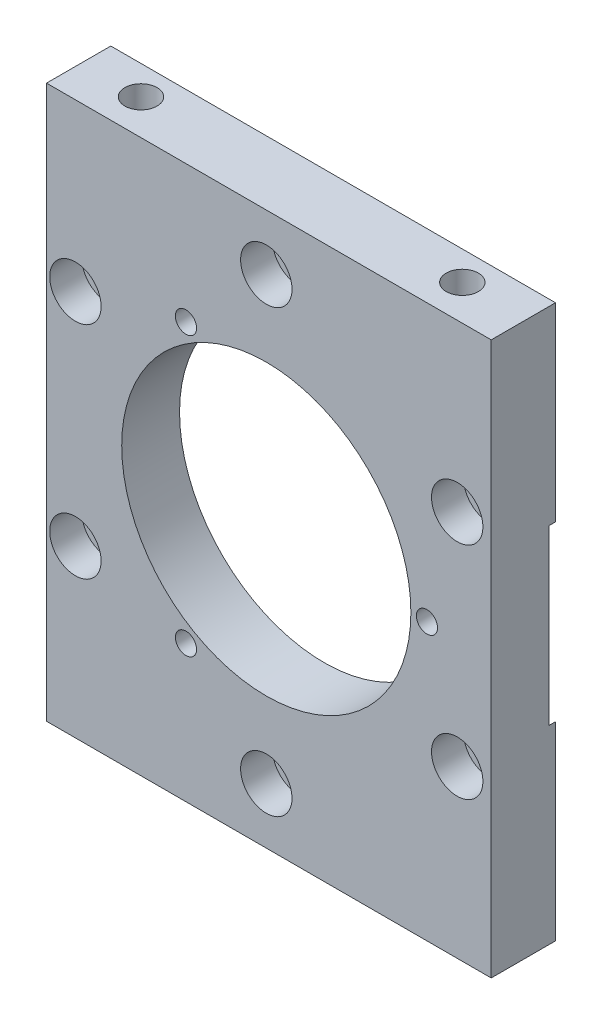
from build123d import *

# Parameters (mm, degrees)
CROQUIS1_W                = 69.2
CROQUIS1_H                = 86
CROQUIS1_R                = 22.5
CROQUIS1_R_2              = 2.75
SALIENTE_EXTRUIR1_DEPTH   = 5
CROQUIS8_R                = 4
CORTAR_EXTRUIR3_DEPTH     = 5
TALADRO_ROSCADO_M42_D     = 3.3
TALADRO_ROSCADO_M62_D     = 5
TALADRO_ROSCADO_M62_DEPTH = 18
TALADRO_ROSCADO_M62_TIP   = 1.502151548
TALADRO_ROSCADO_M63_D     = 5
TALADRO_ROSCADO_M63_DEPTH = 18
TALADRO_ROSCADO_M63_TIP   = 1.502151548
CROQUIS15_R               = 37.5
CORTAR_EXTRUIR4_DEPTH     = 1


with BuildPart() as part:
    # Croquis1 → Saliente-Extruir1 (new body, symmetric)
    with BuildSketch(Plane.XY):
        with Locations((0.4, 0)):
            Rectangle(CROQUIS1_W, CROQUIS1_H)
        Circle(CROQUIS1_R, mode=Mode.SUBTRACT)
        with Locations((0, 34.3)):
            Circle(CROQUIS1_R_2, mode=Mode.SUBTRACT)
        with Locations((29.70467135, 17.15)):
            Circle(CROQUIS1_R_2, mode=Mode.SUBTRACT)
        with Locations((29.70467135, -17.15)):
            Circle(CROQUIS1_R_2, mode=Mode.SUBTRACT)
        with Locations((0, -34.3)):
            Circle(CROQUIS1_R_2, mode=Mode.SUBTRACT)
        with Locations((-29.70467135, -17.15)):
            Circle(CROQUIS1_R_2, mode=Mode.SUBTRACT)
        with Locations((-29.70467135, 17.15)):
            Circle(CROQUIS1_R_2, mode=Mode.SUBTRACT)
    extrude(amount=SALIENTE_EXTRUIR1_DEPTH, both=True)

    # Croquis8 → Cortar-Extruir3 (cut)
    with BuildSketch(Plane.XY.offset(5)):
        with Locations((-29.70467135, 17.15)):
            Circle(CROQUIS8_R)
        with Locations((0, 34.3)):
            Circle(CROQUIS8_R)
        with Locations((29.70467135, 17.15)):
            Circle(CROQUIS8_R)
        with Locations((29.70467135, -17.15)):
            Circle(CROQUIS8_R)
        with Locations((0, -34.3)):
            Circle(CROQUIS8_R)
        with Locations((-29.70467135, -17.15)):
            Circle(CROQUIS8_R)
    extrude(amount=-CORTAR_EXTRUIR3_DEPTH, mode=Mode.SUBTRACT)

    # Taladro roscado M42 (through all)
    with Locations(Plane.XY.offset(5)):
        with Locations((-12.5, 21.650635095), (-12.5, -21.650635095), (25, 0)):
            Hole(TALADRO_ROSCADO_M42_D / 2)

    # Taladro roscado M62
    with Locations(Plane(origin=(0, 43, 0), x_dir=(-1, 0, 0), z_dir=(0, 1, 0))):
        with Locations((25, -0.5), (-25, -0.5)):
            Hole(TALADRO_ROSCADO_M62_D / 2, depth=TALADRO_ROSCADO_M62_DEPTH)
            with Locations((0, 0, -(TALADRO_ROSCADO_M62_DEPTH + TALADRO_ROSCADO_M62_TIP / 2))):  # 118° drill point
                Cone(0, TALADRO_ROSCADO_M62_D / 2, TALADRO_ROSCADO_M62_TIP, mode=Mode.SUBTRACT)

    # Taladro roscado M63
    with Locations(Plane.XZ.offset(43)):
        with Locations((-25, -0.5), (25, -0.5)):
            Hole(TALADRO_ROSCADO_M63_D / 2, depth=TALADRO_ROSCADO_M63_DEPTH)
            with Locations((0, 0, -(TALADRO_ROSCADO_M63_DEPTH + TALADRO_ROSCADO_M63_TIP / 2))):  # 118° drill point
                Cone(0, TALADRO_ROSCADO_M63_D / 2, TALADRO_ROSCADO_M63_TIP, mode=Mode.SUBTRACT)

    # Croquis15 → Cortar-Extruir4 (cut)
    with BuildSketch(Plane(origin=(0, 0, -5), x_dir=(-1, 0, 0), z_dir=(0, 0, -1))):
        Circle(CROQUIS15_R)
    extrude(amount=-CORTAR_EXTRUIR4_DEPTH, mode=Mode.SUBTRACT)


solid = part.part
